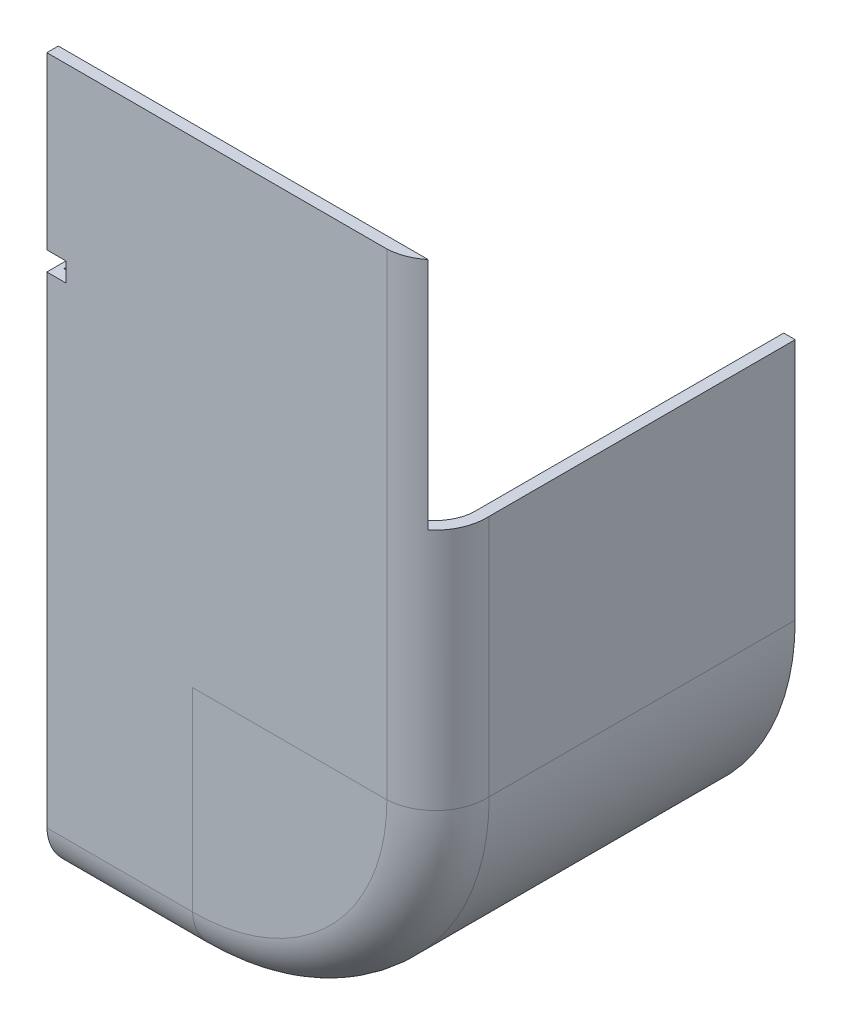
from build123d import *

# Parameters (mm, degrees)
BOSS_EXTRUDE1_DEPTH = 60
SKETCH6_W           = 76.2
SKETCH6_H           = 139.7
BOSS_EXTRUDE3_DEPTH = 3
SKETCH7_W           = 254.695348458
SKETCH7_H           = 135.329086622
CUT_EXTRUDE1_DEPTH  = 76.2
SKETCH8_W           = 10
SKETCH8_H           = 5
CUT_EXTRUDE2_DEPTH  = 172.74190537
SKETCH9_W           = 55
SKETCH9_H           = 40
CUT_EXTRUDE3_DEPTH  = 246.885251985
SKETCH10_W          = 200.764393162
SKETCH10_H          = 14.388440844
CUT_EXTRUDE4_DEPTH  = 15
BOSS_EXTRUDE4_DEPTH = 4
BOSS_EXTRUDE5_DEPTH = 4
SKETCH13_W          = 162.798604232
SKETCH13_H          = 246.735608635
CUT_EXTRUDE5_DEPTH  = 101.6


with BuildPart() as part:
    # Sketch1 → Boss-Extrude1 (new body)
    with BuildSketch(Plane.XY):
        with BuildLine():
            Line((-101.6, 101.6), (-101.6, -38.1))
            ThreePointArc((-101.6, -38.1), (-83.001280605, -83.001280605), (-38.1, -101.6))
            Line((-38.1, -101.6), (38.1, -101.6))
            ThreePointArc((38.1, -101.6), (83.001280605, -83.001280605), (101.6, -38.1))
            Line((101.6, -38.1), (101.6, 101.6))
            Line((101.6, 101.6), (-101.6, 101.6))
        make_face()
        with BuildLine():
            Line((-98.6, 98.6), (-98.6, -38.1))
            ThreePointArc((-98.6, -38.1), (-80.879960262, -80.879960262), (-38.1, -98.6))
            Line((-38.1, -98.6), (38.1, -98.6))
            ThreePointArc((38.1, -98.6), (80.879960262, -80.879960262), (98.6, -38.1))
            Line((98.6, -38.1), (98.6, 98.6))
            Line((98.6, 98.6), (-98.6, 98.6))
        make_face(mode=Mode.SUBTRACT)
    extrude(amount=BOSS_EXTRUDE1_DEPTH)

    # Sweep2: sweep along a path in Sketch5
    with BuildLine(Plane.XY.offset(60)) as sweep2_path:
        Line((-100.1, 101.6), (-100.1, -38.1))
        ThreePointArc((-100.1, -38.1), (-81.940620434, -81.940620434), (-38.1, -100.1))
        Line((-38.1, -100.1), (38.1, -100.1))
        ThreePointArc((38.1, -100.1), (81.940620434, -81.940620434), (100.1, -38.1))
        Line((100.1, -38.1), (100.1, 101.6))
    # Sketch3 → Sweep2 (sweep)
    with BuildSketch(Plane(origin=(0, 101.6, 0), x_dir=(1, 0, 0), z_dir=(0, 1, 0))):
        with BuildLine():
            Line((-38.1, -91.039099262), (-88.9, -91.039099262))
            ThreePointArc((-88.9, -91.039099262), (-95.981959893, -87.480761361), (-98.6, -80))
            Line((-98.6, -80), (-98.6, -60))
            Line((-98.6, -60), (-101.6, -60))
            Line((-101.6, -60), (-101.6, -80))
            ThreePointArc((-101.6, -80), (-98.157592659, -89.649805752), (-88.9, -94.039099262))
            Line((-88.9, -94.039099262), (-38.1, -94.039099262))
            Line((-38.1, -94.039099262), (-38.1, -91.039099262))
        make_face()
    sweep(path=sweep2_path.line)

    # Sketch6 → Boss-Extrude3 (add)
    with BuildSketch(Plane.XY.offset(94.039099262)):
        with Locations((0, 31.75)):
            Rectangle(SKETCH6_W, SKETCH6_H)
    extrude(amount=-BOSS_EXTRUDE3_DEPTH)

    # Sketch7 → Cut-Extrude1 (cut)
    with BuildSketch(Plane(origin=(0, 101.6, 0), x_dir=(1, 0, 0), z_dir=(0, 1, 0))):
        with Locations((-4.889183354, -23.374555951)):
            Rectangle(SKETCH7_W, SKETCH7_H)
    extrude(amount=-CUT_EXTRUDE1_DEPTH, mode=Mode.SUBTRACT)

    # Sketch8 → Cut-Extrude2 (cut, through all)
    with BuildSketch(Plane.XY.offset(94.039099262)):
        with Locations((0, 39.440517612)):
            Rectangle(SKETCH8_W, SKETCH8_H)
    extrude(amount=-CUT_EXTRUDE2_DEPTH, mode=Mode.SUBTRACT)

    # Sketch9 → Cut-Extrude3 (cut, through all)
    with BuildSketch(Plane(origin=(0, -101.6, 0), x_dir=(-1, 0, 0), z_dir=(0, -1, 0))):
        with Locations((0, -20)):
            Rectangle(SKETCH9_W, SKETCH9_H)
    extrude(amount=-CUT_EXTRUDE3_DEPTH, mode=Mode.SUBTRACT)

    # Sketch10 → Cut-Extrude4 (cut)
    with BuildSketch(Plane(origin=(0, 101.6, 0), x_dir=(1, 0, 0), z_dir=(0, 1, 0))):
        with Locations((0, -94.039099262)):
            Rectangle(SKETCH10_W, SKETCH10_H)
    extrude(amount=-CUT_EXTRUDE4_DEPTH, mode=Mode.SUBTRACT)

    # Sketch11 → Boss-Extrude4 (add)
    with BuildSketch(Plane(origin=(0, -98.6, 0), x_dir=(1, 0, 0), z_dir=(0, 1, 0))):
        Polygon((0, -80), (1.5, -80), (1.5, -40), (0, -40), (-1.5, -40), (-1.5, -80), align=None)
    extrude(amount=BOSS_EXTRUDE4_DEPTH)

    # Sketch12 → Boss-Extrude5 (add)
    with BuildSketch(Plane(origin=(0, 0, 91.039099262), x_dir=(-1, 0, 0), z_dir=(0, 0, -1))):
        Polygon((-1.5, -88.9), (0, -88.9), (1.5, -88.9), (1.5, 36.940517612), (-1.5, 36.940517612), align=None)
    extrude(amount=BOSS_EXTRUDE5_DEPTH)

    # Sketch13 → Cut-Extrude5 (cut)
    with BuildSketch(Plane.ZY.offset(101.6)):
        with Locations((24.668934791, -31.353857456)):
            Rectangle(SKETCH13_W, SKETCH13_H)
    extrude(amount=-CUT_EXTRUDE5_DEPTH, mode=Mode.SUBTRACT)


with BuildPart() as cut_extrude5_kept_piece:
    # of the separate pieces the step leaves, the one the design keeps (cut_extrude5_pieces_kept)
    add(part.part.solids().sort_by_distance((0, 86.6, 91.039099262))[0])


solid = cut_extrude5_kept_piece.part
